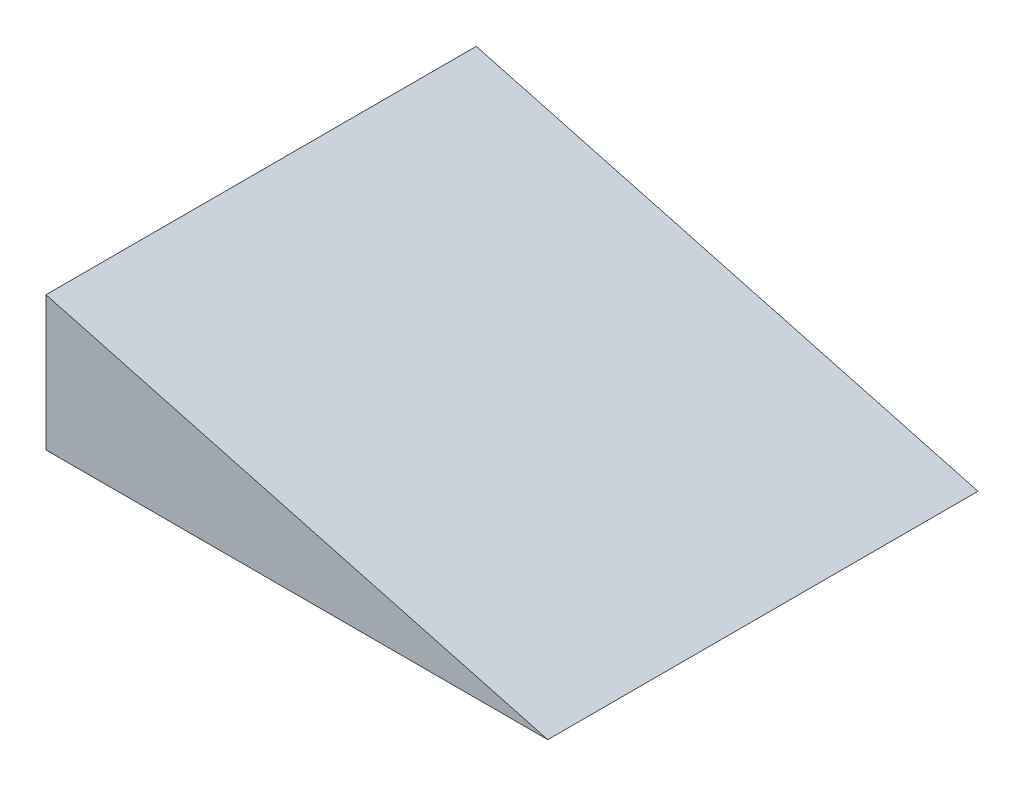
from build123d import *

# Parameters (mm, degrees)
BOSS_EXTRUDE1_DEPTH = 406.4


with BuildPart() as part:
    # Sketch1 → Boss-Extrude1 (new body)
    with BuildSketch(Plane.XY):
        Polygon((0, 0), (0, 127), (473.970452561, 0), align=None)
    extrude(amount=-BOSS_EXTRUDE1_DEPTH)


solid = part.part
